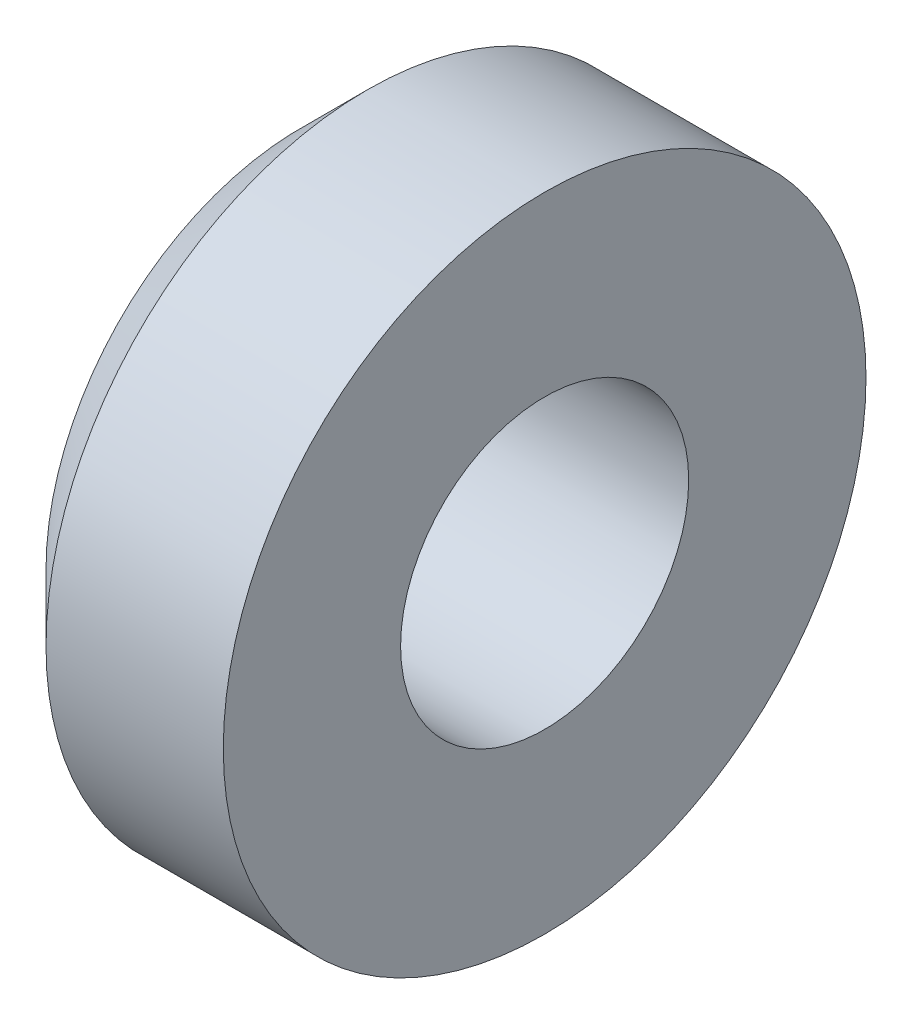
from build123d import *


with BuildPart() as part:
    # Sketch1 → Revolve1 (revolve)
    with BuildSketch(Plane.XY):
        Polygon((0, 2.875), (0.75, 3.625), (2.75, 3.625), (2.75, 1.625), (0, 1.625), align=None)
    revolve(axis=Axis((-4.994959257, 0, 0), (1, 0, 0)))


solid = part.part
